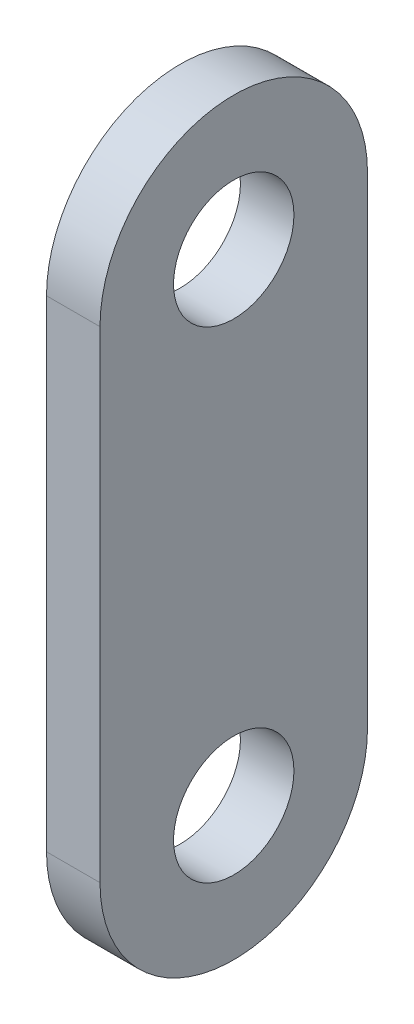
from build123d import *

# Parameters (mm, degrees)
BOSS_EXTRUDE1_DEPTH = 3.175
CUT_EXTRUDE1_REACH  = 8.35
SKETCH2_R           = 7.14375


with BuildPart() as part:
    # Sketch1 → Boss-Extrude1 (new body, symmetric)
    with BuildSketch(Plane(origin=(0, 0, 0), x_dir=(0, 0, -1), z_dir=(1, 0, 0))):
        with BuildLine():
            Line((-15.875, -28.575), (-15.875, 28.575))
            ThreePointArc((-15.875, 28.575), (0, 44.45), (15.875, 28.575))
            Line((15.875, 28.575), (15.875, -28.575))
            ThreePointArc((15.875, -28.575), (0, -44.45), (-15.875, -28.575))
        make_face()
    extrude(amount=BOSS_EXTRUDE1_DEPTH, both=True)

    # Sketch2 → Cut-Extrude1 (cut, up to next)
    with BuildSketch(Plane(origin=(3.175, 0, 0), x_dir=(0, 0, -1), z_dir=(1, 0, 0)), mode=Mode.PRIVATE) as cut_extrude1_sk1:
        with Locations((0, 28.575)):
            Circle(SKETCH2_R)
    cut_extrude1_tool1 = extrude(cut_extrude1_sk1.sketch, amount=-CUT_EXTRUDE1_REACH, mode=Mode.PRIVATE) & part.part
    add(cut_extrude1_tool1.solids().sort_by_distance((3.175, 28.575, 0))[0], mode=Mode.SUBTRACT)
    # Sketch2 → Cut-Extrude1 (cut, up to next)
    with BuildSketch(Plane(origin=(3.175, 0, 0), x_dir=(0, 0, -1), z_dir=(1, 0, 0)), mode=Mode.PRIVATE) as cut_extrude1_sk2:
        with Locations((0, -28.575)):
            Circle(SKETCH2_R)
    cut_extrude1_tool2 = extrude(cut_extrude1_sk2.sketch, amount=-CUT_EXTRUDE1_REACH, mode=Mode.PRIVATE) & part.part
    add(cut_extrude1_tool2.solids().sort_by_distance((3.175, -28.575, 0))[0], mode=Mode.SUBTRACT)


solid = part.part
